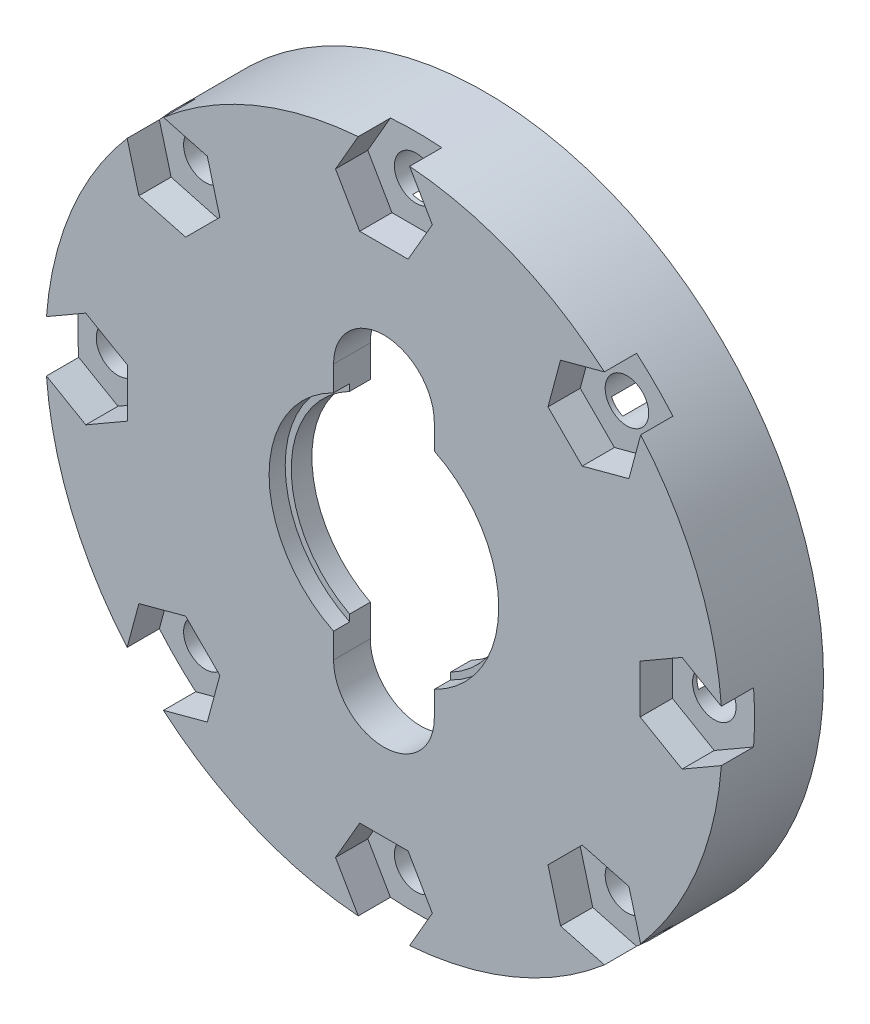
from build123d import *

# Parameters (mm, degrees)
SKETCH3_R           = 21
BOSS_EXTRUDE2_DEPTH = 1
SKETCH4_R           = 21
BOSS_EXTRUDE3_DEPTH = 5.28
SKETCH5_R           = 17.25
CUT_EXTRUDE1_DEPTH  = 4
CUT_EXTRUDE2_DEPTH  = 2
SKETCH8_R           = 1.35
CUT_EXTRUDE4_DEPTH  = 31.355203837
CIRPATTERN1_COUNT   = 8
CUT_EXTRUDE5_DEPTH  = 31.355203837


with BuildPart() as part:
    # Sketch3 → Boss-Extrude2 (new body)
    with BuildSketch(Plane.XY):
        Circle(SKETCH3_R)
        with BuildLine():
            Line((-3.124988, -6.403130094), (-3.124988, -7.949679))
            Line((-3.124988, -7.949679), (3.125012, -7.949679))
            Line((3.125012, -7.949679), (3.125012, -6.403118381))
            ThreePointArc((3.125012, -6.403118381), (7.125, 0), (3.125012, 6.403118381))
            Line((3.125012, 6.403118381), (3.125012, 7.949431))
            Line((3.125012, 7.949431), (-3.124988, 7.949431))
            Line((-3.124988, 7.949431), (-3.124988, 6.403130094))
            ThreePointArc((-3.124988, 6.403130094), (-7.125, 0), (-3.124988, -6.403130094))
        make_face(mode=Mode.SUBTRACT)
    extrude(amount=-BOSS_EXTRUDE2_DEPTH)

    # Sketch4 → Boss-Extrude3 (add)
    with BuildSketch(Plane(origin=(0, 0, -1), x_dir=(-1, 0, 0), z_dir=(0, 0, -1))):
        Circle(SKETCH4_R)
        with BuildLine():
            Line((2.749988, 6.164419356), (2.749988, 7.574431))
            Line((2.749988, 7.574431), (-2.750012, 7.574431))
            Line((-2.750012, 7.574431), (-2.750012, 6.16440865))
            ThreePointArc((-2.750012, 6.16440865), (-6.75, 0), (-2.750012, -6.16440865))
            Line((-2.750012, -6.16440865), (-2.750012, -7.574679))
            Line((-2.750012, -7.574679), (2.749988, -7.574679))
            Line((2.749988, -7.574679), (2.749988, -6.164419356))
            ThreePointArc((2.749988, -6.164419356), (6.75, 0), (2.749988, 6.164419356))
        make_face(mode=Mode.SUBTRACT)
    extrude(amount=BOSS_EXTRUDE3_DEPTH)

    # Sketch5 → Cut-Extrude1 (cut)
    with BuildSketch(Plane(origin=(0, 0, -6.28), x_dir=(-1, 0, 0), z_dir=(0, 0, -1))):
        Circle(SKETCH5_R)
    extrude(amount=-CUT_EXTRUDE1_DEPTH, mode=Mode.SUBTRACT)

    # Sketch6 → Cut-Extrude2 (cut)
    with BuildSketch(Plane.XY):
        Polygon((-21.1, -1.5011107), (-18.5, -3.0022214), (-15.9, -1.5011107), (-15.9, 1.5011107), (-18.5, 3.0022214), (-21.1, 1.5011107), align=None)
    cut_extrude2 = extrude(amount=-CUT_EXTRUDE2_DEPTH, mode=Mode.SUBTRACT)

    # Sketch8 → Cut-Extrude4 (cut, through all)
    with BuildSketch(Plane.XY):
        with Locations((-18.5, 0)):
            Circle(SKETCH8_R)
    cut_extrude4 = extrude(amount=-CUT_EXTRUDE4_DEPTH, mode=Mode.SUBTRACT)

    # CirPattern1: Cut-Extrude2, Cut-Extrude4 ×8 about axis
    cirpattern1_axis = Axis((0, 0, -6.594), (0, 0, 1))
    add([cut_extrude2.rotate(cirpattern1_axis, i * 360 / CIRPATTERN1_COUNT) for i in range(1, CIRPATTERN1_COUNT)], mode=Mode.SUBTRACT)
    add([cut_extrude4.rotate(cirpattern1_axis, i * 360 / CIRPATTERN1_COUNT) for i in range(1, CIRPATTERN1_COUNT)], mode=Mode.SUBTRACT)

    # Sketch9 → Cut-Extrude5 (cut, through all)
    with BuildSketch(Plane.XY):
        with BuildLine():
            Line((3.125012, 7.949431), (3.125012, -7.949431))
            ThreePointArc((3.125012, -7.949431), (1.2e-05, -11.074431), (-3.124988, -7.949431))
            Line((-3.124988, -7.949431), (-3.124988, 7.949431))
            ThreePointArc((-3.124988, 7.949431), (1.2e-05, 11.074431), (3.125012, 7.949431))
        make_face()
    extrude(amount=-CUT_EXTRUDE5_DEPTH, mode=Mode.SUBTRACT)


solid = part.part
